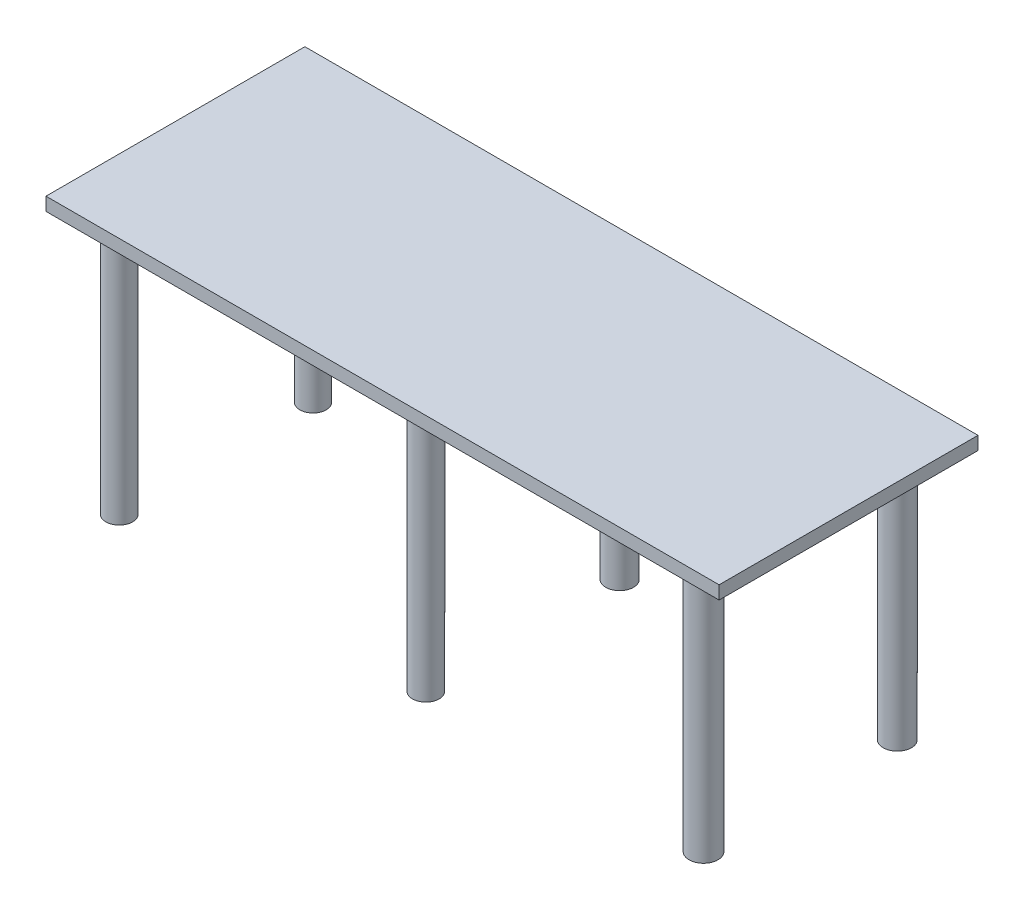
from build123d import *

# Parameters (mm, degrees)
CROQUIS1_W              = 1300
CROQUIS1_H              = 25.535714286
SALIENTE_EXTRUIR1_DEPTH = 500
CROQUIS2_R              = 25.810333558
CROQUIS2_R_2            = 25.368411914
CROQUIS2_R_3            = 27.841445981
CROQUIS2_R_4            = 26.795222898
CROQUIS2_R_5            = 27.244240978
SALIENTE_EXTRUIR2_DEPTH = 500


with BuildPart() as part:
    # Croquis1 → Saliente-Extruir1 (new body)
    with BuildSketch(Plane.XY):
        with Locations((-33.200611326, 136.964285714)):
            Rectangle(CROQUIS1_W, CROQUIS1_H)
    extrude(amount=SALIENTE_EXTRUIR1_DEPTH)

    # Croquis2 → Saliente-Extruir2 (add)
    with BuildSketch(Plane.XZ.offset(-124.196428571)):
        with Locations((-606.046625582, 435.691010879)):
            Circle(CROQUIS2_R)
        with Locations((-606.046625582, 61.441174281)):
            Circle(CROQUIS2_R_2)
        with Locations((-13.842861157, 435.691010879)):
            Circle(CROQUIS2_R)
        with Locations((522.438513892, 435.691010879)):
            Circle(CROQUIS2_R_3)
        with Locations((-13.842861157, 61.441174281)):
            Circle(CROQUIS2_R_4)
        with Locations((522.438513892, 61.441174281)):
            Circle(CROQUIS2_R_5)
    extrude(amount=SALIENTE_EXTRUIR2_DEPTH)


solid = part.part
